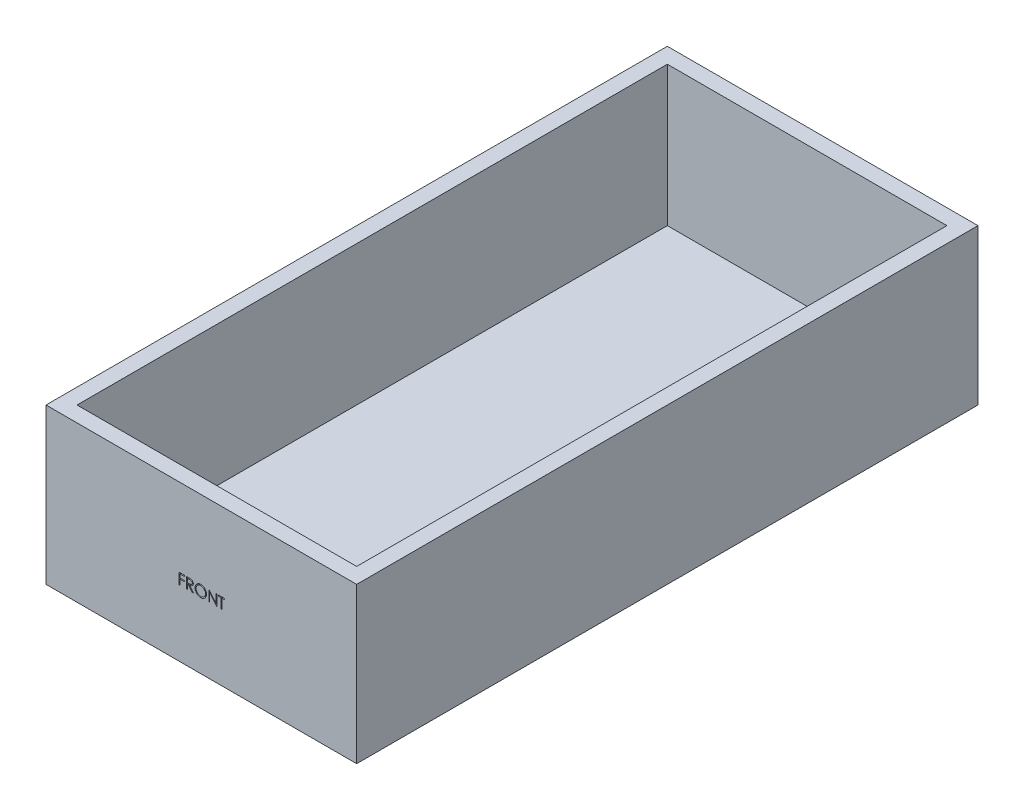
from build123d import *

# Parameters (mm, degrees)
SKETCH1_W           = 100
SKETCH1_H           = 200
BOSS_EXTRUDE1_DEPTH = 50
SHELL1_T            = -5
CUT_EXTRUDE1_DEPTH  = 1


with BuildPart() as part:
    # Sketch1 → Boss-Extrude1 (new body)
    with BuildSketch(Plane(origin=(0, 0, 0), x_dir=(1, 0, 0), z_dir=(0, 1, 0))):
        Rectangle(SKETCH1_W, SKETCH1_H)
    extrude(amount=BOSS_EXTRUDE1_DEPTH)

    # Shell1
    shell1_openings = [part.faces().sort_by_distance(p)[0] for p in [
        (0, 50, 0),
    ]]
    offset(amount=SHELL1_T, openings=shell1_openings, kind=Kind.INTERSECTION)

    # Sketch2 → Cut-Extrude1 (cut)
    # profile 1 of 5: a face of its own
    with BuildSketch(Plane.XY.offset(100)):
        Polygon((-7.122434805, 24.811392935), (-5.4173066, 24.811392935), (-5.4173066, 24.452418576), (-6.808332241, 24.452418576), (-6.808332241, 23.3754955), (-5.4173066, 23.3754955), (-5.4173066, 23.016521141), (-6.808332241, 23.016521141), (-6.808332241, 21.311392935), (-7.122434805, 21.311392935), align=None)
    # profile 2 of 5: a face of its own
    with BuildSketch(Plane.XY.offset(100)):
        with BuildLine():
            Line((-4.789101471, 24.811392935), (-4.088680798, 24.811392935))
            add(Edge.make_bspline(
                [(-4.088680798, 24.811392935), (-4.04193967, 24.811237349), (-3.952191525, 24.810938607), (-3.823618255, 24.809272844), (-3.706791158, 24.804498488), (-3.601771319, 24.800389905), (-3.508560664, 24.792897964), (-3.426873373, 24.785737317), (-3.357085675, 24.776363656), (-3.314839824, 24.767658233), (-3.295712048, 24.763716653)],
                knots=[0, 0, 0, 0, 1.410062039, 2.707475311, 3.878576406, 4.937260626, 5.877586885, 6.699081471, 7.410979367, 8, 8, 8, 8], degree=3))
            add(Edge.make_bspline(
                [(-3.295712048, 24.763716653), (-3.270105424, 24.757389888), (-3.219438435, 24.744871324), (-3.146488369, 24.718411724), (-3.076974045, 24.687792099), (-3.01118422, 24.651828379), (-2.949448429, 24.610253599), (-2.891130118, 24.563785476), (-2.835964655, 24.512678271), (-2.786183025, 24.455643429), (-2.739243973, 24.39580692), (-2.699655347, 24.331103163), (-2.665528867, 24.263441635), (-2.63835835, 24.192134217), (-2.616480376, 24.117872446), (-2.601054137, 24.039983649), (-2.591802949, 23.958822674), (-2.590861094, 23.903464765), (-2.590383523, 23.875395339)],
                knots=[0, 0, 0, 0, 1.027469482, 2.033020251, 3.019912614, 3.986113645, 4.951240523, 5.91722682, 6.890402269, 7.87763091, 8.8651537, 9.85103654, 10.82876324, 11.815024772, 12.821070561, 13.842952187, 14.906261191, 16, 16, 16, 16], degree=3))
            add(Edge.make_bspline(
                [(-2.590383523, 23.875395339), (-2.591852521, 23.828760235), (-2.594718916, 23.737763067), (-2.62144402, 23.605702185), (-2.66522054, 23.482512871), (-2.725543829, 23.368350233), (-2.802363305, 23.265439587), (-2.894688096, 23.175049132), (-3.002569707, 23.09940922), (-3.102999023, 23.046956415), (-3.191713223, 23.013363506), (-3.264746536, 22.989727147), (-3.344413513, 22.971465182), (-3.429950848, 22.95510505), (-3.521714503, 22.942753356), (-3.619484543, 22.933706761), (-3.723330694, 22.928052713), (-3.794669764, 22.927210708), (-3.8313691, 22.926777551)],
                knots=[0, 0, 0, 0, 1.260483769, 2.459530307, 3.627416485, 4.787058657, 5.939039949, 7.08810263, 8.267026773, 9.491475466, 10.141966685, 10.831826277, 11.566392101, 12.351337768, 13.187381173, 14.07005841, 15.007169909, 16, 16, 16, 16], degree=3))
            Line((-3.8313691, 22.926777551), (-2.545511728, 21.311392935))
            Line((-2.545511728, 21.311392935), (-2.933933202, 21.311392935))
            Line((-2.933933202, 21.311392935), (-4.219790574, 22.926777551))
            Line((-4.219790574, 22.926777551), (-4.474998907, 22.926777551))
            Line((-4.474998907, 22.926777551), (-4.474998907, 21.311392935))
            Line((-4.474998907, 21.311392935), (-4.789101471, 21.311392935))
            Line((-4.789101471, 21.311392935), (-4.789101471, 24.811392935))
        make_face()
        with BuildLine():
            Line((-4.474998907, 24.452418576), (-4.474998907, 23.28575191))
            Line((-4.474998907, 23.28575191), (-3.834173587, 23.280844057))
            add(Edge.make_bspline(
                [(-3.834173587, 23.280844057), (-3.804253548, 23.280830821), (-3.746259991, 23.280805164), (-3.662359326, 23.28479894), (-3.584239214, 23.289342259), (-3.512198462, 23.296291604), (-3.446204887, 23.305247676), (-3.386291473, 23.31645066), (-3.332360422, 23.329502723), (-3.269461883, 23.349704349), (-3.199225352, 23.381710367), (-3.122893892, 23.428275866), (-3.057891554, 23.486844985), (-3.002973692, 23.553818441), (-2.95884426, 23.62745469), (-2.927732206, 23.706871059), (-2.907989764, 23.790062657), (-2.905661218, 23.847240765), (-2.904486087, 23.876096461)],
                knots=[0, 0, 0, 0, 1.146690395, 2.22261258, 3.21895312, 4.145990853, 4.996080663, 5.770904154, 6.481378293, 7.121626537, 8.300444488, 9.431385265, 10.535395872, 11.636531494, 12.74115979, 13.810798291, 14.895190096, 16, 16, 16, 16], degree=3))
            add(Edge.make_bspline(
                [(-2.904486087, 23.876096461), (-2.905688208, 23.904243035), (-2.908070373, 23.960019273), (-2.927519142, 24.041675184), (-2.960408523, 24.118742134), (-3.004730761, 24.190906619), (-3.058729916, 24.256412355), (-3.122047729, 24.312459508), (-3.192952924, 24.358708972), (-3.259224122, 24.388263353), (-3.318458335, 24.406383206), (-3.369887995, 24.41913437), (-3.427999472, 24.429378839), (-3.493074931, 24.4375869), (-3.564836562, 24.444641844), (-3.643647213, 24.449393623), (-3.728983993, 24.452207487), (-3.788130924, 24.452346576), (-3.818748907, 24.452418576)],
                knots=[0, 0, 0, 0, 1.101028733, 2.181837193, 3.264309656, 4.369019818, 5.486613113, 6.575447106, 7.666700264, 8.788928104, 9.402425223, 10.0903467, 10.862060571, 11.710948788, 12.657782767, 13.684531032, 14.801375019, 16, 16, 16, 16], degree=3))
            Line((-3.818748907, 24.452418576), (-4.474998907, 24.452418576))
        make_face(mode=Mode.SUBTRACT)
    # profile 3 of 5: a face of its own
    with BuildSketch(Plane.XY.offset(100)):
        with BuildLine():
            add(Edge.make_bspline(
                [(-0.189742497, 24.901136525), (-0.124934391, 24.899495046), (0.002354076, 24.896271045), (0.189428974, 24.871591941), (0.368024069, 24.828896551), (0.539594208, 24.772033569), (0.702087184, 24.696179183), (0.856726077, 24.604494035), (1.003142951, 24.496017576), (1.139364332, 24.37158835), (1.264021282, 24.236204896), (1.373847169, 24.091726986), (1.465889462, 23.939028183), (1.54147525, 23.778567353), (1.600773859, 23.610707385), (1.641692903, 23.434553382), (1.667831053, 23.251246692), (1.670886831, 23.126219827), (1.67243699, 23.062795179)],
                knots=[0, 0, 0, 0, 1.065120563, 2.091984664, 3.0946048, 4.079830382, 5.057816894, 6.036188127, 7.030412546, 8.04752943, 9.064399622, 10.05169764, 11.02544977, 11.989514704, 12.962713494, 13.945757189, 14.957906945, 16, 16, 16, 16], degree=3))
            add(Edge.make_bspline(
                [(1.67243699, 23.062795179), (1.670887058, 22.999837733), (1.667831961, 22.875741312), (1.641663184, 22.693597868), (1.600622184, 22.518507172), (1.542025917, 22.350761519), (1.466800439, 22.190183955), (1.374145268, 22.037197001), (1.265004057, 21.891750503), (1.140797206, 21.755437838), (1.005396164, 21.630440367), (0.860165897, 21.521521491), (0.708372577, 21.427797367), (0.548062869, 21.353013693), (0.381362832, 21.293241772), (0.206780509, 21.252489142), (0.025133955, 21.226202099), (-0.098737049, 21.223183583), (-0.161697625, 21.221649346)],
                knots=[0, 0, 0, 0, 1.043624062, 2.057103931, 3.04512605, 4.022047818, 4.998200453, 5.980619268, 6.982898556, 8.009068085, 9.034988726, 10.034168286, 11.015286542, 11.987931943, 12.962482838, 13.94673481, 14.956375938, 16, 16, 16, 16], degree=3))
            add(Edge.make_bspline(
                [(-0.161697625, 21.221649346), (-0.225121944, 21.223198733), (-0.35014816, 21.226252986), (-0.533685195, 21.252434391), (-0.709962939, 21.293375695), (-0.878477291, 21.351885131), (-1.03932222, 21.427502362), (-1.192812303, 21.519706741), (-1.33833145, 21.629113882), (-1.474673197, 21.753280457), (-1.599422395, 21.888452009), (-1.70818177, 22.033286264), (-1.800406884, 22.184941721), (-1.875770216, 22.343839245), (-1.935434676, 22.509210687), (-1.976139494, 22.682159165), (-2.002475446, 22.861698671), (-2.005510292, 22.983941569), (-2.007050189, 23.045968256)],
                knots=[0, 0, 0, 0, 1.053102029, 2.075944431, 3.073151272, 4.055350789, 5.033113405, 6.020478099, 7.024410459, 8.052272461, 9.079885166, 10.07527673, 11.055994387, 12.023226415, 12.992069828, 13.970394897, 14.97016774, 16, 16, 16, 16], degree=3))
            add(Edge.make_bspline(
                [(-2.007050189, 23.045968256), (-2.006515554, 23.087600925), (-2.005453027, 23.170341049), (-1.992661335, 23.293207649), (-1.974099634, 23.414098306), (-1.947497721, 23.532669254), (-1.912706054, 23.648630239), (-1.871654027, 23.762781002), (-1.821514181, 23.873964726), (-1.764833533, 23.982708117), (-1.701571725, 24.087316023), (-1.631695976, 24.186195606), (-1.557660607, 24.280176603), (-1.476497214, 24.366823607), (-1.390880769, 24.448657263), (-1.299422391, 24.52441998), (-1.202680146, 24.594794931), (-1.100237766, 24.658215272), (-0.994619492, 24.715574407), (-0.885742714, 24.764796258), (-0.775086142, 24.80704232), (-0.662131494, 24.841283145), (-0.547178722, 24.868315181), (-0.429976938, 24.886722535), (-0.310619511, 24.899546852), (-0.230208192, 24.900604354), (-0.189742497, 24.901136525)],
                knots=[0, 0, 0, 0, 1.037015668, 2.060948919, 3.074880161, 4.083647147, 5.086022904, 6.090072063, 7.104153813, 8.122640571, 9.144368836, 10.147691507, 11.138137339, 12.123020368, 13.103399296, 14.087645067, 15.080126199, 16.082011238, 17.087798457, 18.072939717, 19.057185487, 20.037253025, 21.01195951, 21.997135196, 22.992090687, 24, 24, 24, 24], degree=3))
        make_face()
        with BuildLine():
            add(Edge.make_bspline(
                [(-0.174317817, 24.542162166), (-0.207532451, 24.541757276), (-0.273644184, 24.540951366), (-0.37192872, 24.530335651), (-0.468920654, 24.515205762), (-0.564640016, 24.493624241), (-0.658686306, 24.464220188), (-0.751936147, 24.43037928), (-0.843539201, 24.389158189), (-0.933193058, 24.342585485), (-1.020108134, 24.291036564), (-1.102120835, 24.234064797), (-1.179443479, 24.173006243), (-1.251886746, 24.107718405), (-1.319237918, 24.037868804), (-1.382822619, 23.964516368), (-1.440092201, 23.885564477), (-1.492577778, 23.80315407), (-1.539545618, 23.717392488), (-1.581310973, 23.629182626), (-1.615474982, 23.537804939), (-1.643337358, 23.444250782), (-1.666437169, 23.348668322), (-1.681071093, 23.250332473), (-1.691803452, 23.149737361), (-1.692563298, 23.081755507), (-1.692947625, 23.0473705)],
                knots=[0, 0, 0, 0, 1.008559885, 2.007477868, 2.99961109, 3.989939068, 4.984837346, 5.991145699, 7.001802488, 8.033829008, 9.059044045, 10.069351652, 11.065060232, 12.050310815, 13.029377138, 14.011219647, 14.996725999, 15.989392538, 16.977580475, 17.965360261, 18.951710183, 19.937753436, 20.929683414, 21.935841486, 22.955955122, 24, 24, 24, 24], degree=3))
            add(Edge.make_bspline(
                [(-1.692947625, 23.0473705), (-1.691672763, 22.996808279), (-1.689164715, 22.897336748), (-1.667207145, 22.751568605), (-1.633385171, 22.611480318), (-1.583527804, 22.477838409), (-1.52117719, 22.349494126), (-1.444150299, 22.227586021), (-1.352891214, 22.112081147), (-1.249227687, 22.003785878), (-1.135904981, 21.904940074), (-1.015572251, 21.818176665), (-0.889518643, 21.744766415), (-0.757415441, 21.684961343), (-0.619967901, 21.637571605), (-0.47629035, 21.605092974), (-0.327339891, 21.583717519), (-0.225809236, 21.581664763), (-0.174317817, 21.580623705)],
                knots=[0, 0, 0, 0, 1.032063989, 2.030389145, 3.003944642, 3.970395727, 4.937377036, 5.913328081, 6.909231446, 7.93887556, 8.970685674, 9.976071282, 10.964166581, 11.944589148, 12.933237628, 13.927779006, 14.949070134, 16, 16, 16, 16], degree=3))
            add(Edge.make_bspline(
                [(-0.174317817, 21.580623705), (-0.139708316, 21.581099209), (-0.071067279, 21.582042277), (0.031028243, 21.591540954), (0.131284455, 21.606772823), (0.229560734, 21.628703479), (0.325745546, 21.656150685), (0.420240349, 21.688758413), (0.512038639, 21.729439617), (0.602298477, 21.774387568), (0.688694719, 21.825627726), (0.771170251, 21.880665876), (0.847646231, 21.941634496), (0.920035302, 22.005952309), (0.987662991, 22.074916157), (1.050071976, 22.148436379), (1.107052108, 22.226977036), (1.159517754, 22.309262442), (1.206321017, 22.395258694), (1.247100116, 22.483788372), (1.281696232, 22.574633482), (1.309624737, 22.667925053), (1.331510198, 22.763485902), (1.346590118, 22.86144398), (1.357138557, 22.961603323), (1.357933634, 23.029347178), (1.358334426, 23.063496301)],
                knots=[0, 0, 0, 0, 1.047197238, 2.076906641, 3.100256066, 4.114471768, 5.12198147, 6.126382909, 7.136867548, 8.15857795, 9.17633901, 10.174870724, 11.156907918, 12.133735059, 13.104061851, 14.077631395, 15.04955518, 16.038496417, 17.029181396, 18.010275684, 18.986308667, 19.968651475, 20.955262928, 21.950658345, 22.966943676, 24, 24, 24, 24], degree=3))
            add(Edge.make_bspline(
                [(1.358334426, 23.063496301), (1.357933313, 23.097411805), (1.357137632, 23.164689455), (1.346595157, 23.264150274), (1.331494267, 23.361403485), (1.309731559, 23.456067288), (1.281681405, 23.548165813), (1.247094075, 23.637612561), (1.206308775, 23.724740756), (1.159500551, 23.809335053), (1.106884727, 23.890509791), (1.049390484, 23.968112203), (0.986025136, 24.040684945), (0.918599111, 24.110019639), (0.845428226, 24.174637528), (0.766843931, 24.234560049), (0.683800254, 24.291233323), (0.595873018, 24.342358885), (0.505129065, 24.389573118), (0.412015107, 24.430024121), (0.317586007, 24.46439624), (0.222081895, 24.493713205), (0.124698916, 24.515121236), (0.026095087, 24.530349285), (-0.073593171, 24.540947671), (-0.140636391, 24.54175605), (-0.174317817, 24.542162166)],
                knots=[0, 0, 0, 0, 1.02996197, 2.043119294, 3.035359645, 4.018872909, 4.991431989, 5.957985074, 6.929999688, 7.912076566, 8.892894881, 9.867085534, 10.843653904, 11.817741046, 12.803660682, 13.806313499, 14.818574707, 15.856120519, 16.894564902, 17.924820532, 18.937903209, 19.946497019, 20.957711757, 21.963978472, 22.977135795, 24, 24, 24, 24], degree=3))
        make_face(mode=Mode.SUBTRACT)
    # profile 4 of 5: a face of its own
    with BuildSketch(Plane.XY.offset(100)):
        Polygon((2.390385708, 21.311392935), (2.390385708, 24.811392935), (2.456291157, 24.811392935), (4.768590836, 22.056685403), (4.768590836, 24.811392935), (5.0826934, 24.811392935), (5.0826934, 21.311392935), (5.011178977, 21.311392935), (2.704488272, 24.059790371), (2.704488272, 21.311392935), align=None)
    # profile 5 of 5: a face of its own
    with BuildSketch(Plane.XY.offset(100)):
        Polygon((5.576283144, 24.452418576), (5.576283144, 24.811392935), (7.416026734, 24.811392935), (7.416026734, 24.452418576), (6.653206221, 24.452418576), (6.653206221, 21.311392935), (6.339103657, 21.311392935), (6.339103657, 24.452418576), align=None)
    extrude(amount=-CUT_EXTRUDE1_DEPTH, mode=Mode.SUBTRACT)


solid = part.part
